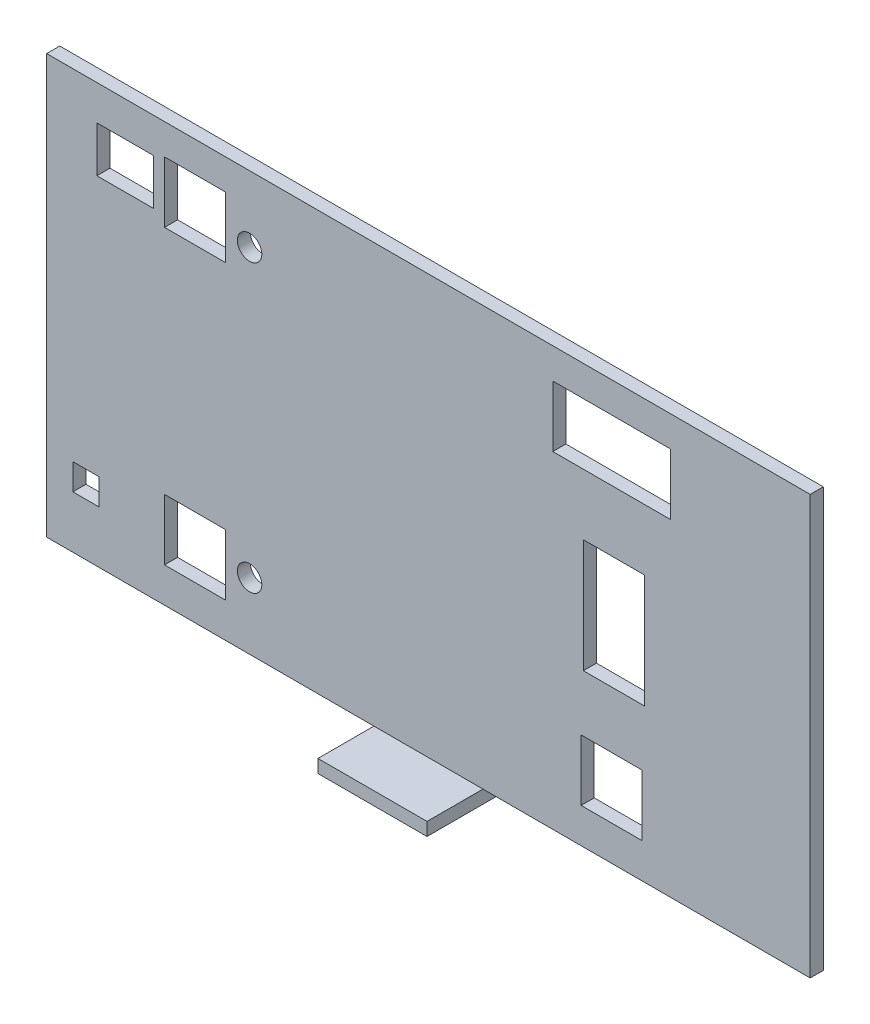
from build123d import *

# Parameters (mm, degrees)
SKETCH2_W           = 175
SKETCH2_H           = 96
BOSS_EXTRUDE1_DEPTH = 3
SKETCH3_W           = 12
SKETCH3_H           = 12
SKETCH3_W_2         = 13
SKETCH3_H_2         = 10.5
SKETCH3_W_3         = 27
SKETCH3_H_3         = 14
CUT_EXTRUDE1_DEPTH  = 10
SKETCH4_W           = 14
SKETCH4_H           = 26
CUT_EXTRUDE2_DEPTH  = 10
SKETCH5_W           = 12
SKETCH5_H           = 12
SKETCH5_W_2         = 6
SKETCH5_H_2         = 6
CUT_EXTRUDE3_DEPTH  = 10
SKETCH7_R           = 2.8
CUT_EXTRUDE4_DEPTH  = 10
SKETCH9_W           = 25
SKETCH9_H           = 15.829859375
BOSS_EXTRUDE2_DEPTH = 3
SKETCH10_W          = 27
SKETCH10_H          = 14
CUT_EXTRUDE5_DEPTH  = 10
SKETCH11_W          = 14
SKETCH11_H          = 14
CUT_EXTRUDE6_DEPTH  = 10
SKETCH12_W          = 14
SKETCH12_H          = 14
CUT_EXTRUDE7_DEPTH  = 10
SKETCH13_W          = 14
SKETCH13_H          = 14
CUT_EXTRUDE8_DEPTH  = 10


with BuildPart() as part:
    # Sketch2 → Boss-Extrude1 (new body)
    with BuildSketch(Plane.XY):
        Rectangle(SKETCH2_W, SKETCH2_H)
    extrude(amount=BOSS_EXTRUDE1_DEPTH)

    # Sketch3 → Cut-Extrude1 (cut)
    with BuildSketch(Plane(origin=(0, 0, 0), x_dir=(-1, 0, 0), z_dir=(0, 0, -1))):
        with Locations((53.5, 34)):
            Rectangle(SKETCH3_W, SKETCH3_H)
        with Locations((69.5, 34.75)):
            Rectangle(SKETCH3_W_2, SKETCH3_H_2)
        with Locations((-42, 34)):
            Rectangle(SKETCH3_W_3, SKETCH3_H_3)
        with Locations((-48.5, 34)):
            Rectangle(SKETCH3_W, SKETCH3_H, mode=Mode.SUBTRACT)
        with Locations((-35.5, 34)):
            Rectangle(SKETCH3_W, SKETCH3_H, mode=Mode.SUBTRACT)
    extrude(amount=-CUT_EXTRUDE1_DEPTH, mode=Mode.SUBTRACT)

    # Sketch4 → Cut-Extrude2 (cut)
    with BuildSketch(Plane(origin=(0, 0, 0), x_dir=(-1, 0, 0), z_dir=(0, 0, -1))):
        with Locations((-42.5, 0)):
            Rectangle(SKETCH4_W, SKETCH4_H)
    extrude(amount=-CUT_EXTRUDE2_DEPTH, mode=Mode.SUBTRACT)

    # Sketch5 → Cut-Extrude3 (cut)
    with BuildSketch(Plane(origin=(0, 0, 0), x_dir=(-1, 0, 0), z_dir=(0, 0, -1))):
        with Locations((-42, -33)):
            Rectangle(SKETCH5_W, SKETCH5_H)
        with Locations((53.5, -33)):
            Rectangle(SKETCH5_W, SKETCH5_H)
        with Locations((78.5, -33)):
            Rectangle(SKETCH5_W_2, SKETCH5_H_2)
    extrude(amount=-CUT_EXTRUDE3_DEPTH, mode=Mode.SUBTRACT)

    # Sketch7 → Cut-Extrude4 (cut)
    with BuildSketch(Plane(origin=(0, 0, 0), x_dir=(-1, 0, 0), z_dir=(0, 0, -1))):
        with Locations((41, 32.8)):
            Circle(SKETCH7_R)
        with Locations((41, -32.8)):
            Circle(SKETCH7_R)
    extrude(amount=-CUT_EXTRUDE4_DEPTH, mode=Mode.SUBTRACT)

    # Sketch9 → Boss-Extrude2 (add)
    with BuildSketch(Plane.XZ.offset(48)):
        with Locations((0, 7.914929688)):
            Rectangle(SKETCH9_W, SKETCH9_H)
    extrude(amount=BOSS_EXTRUDE2_DEPTH)

    # Sketch10 → Cut-Extrude5 (cut)
    with BuildSketch(Plane(origin=(0, 0, 0), x_dir=(-1, 0, 0), z_dir=(0, 0, -1))):
        with Locations((-42, 34)):
            Rectangle(SKETCH10_W, SKETCH10_H)
    extrude(amount=-CUT_EXTRUDE5_DEPTH, mode=Mode.SUBTRACT)

    # Sketch11 → Cut-Extrude6 (cut)
    with BuildSketch(Plane(origin=(0, 0, 0), x_dir=(-1, 0, 0), z_dir=(0, 0, -1))):
        with Locations((53.5, 34)):
            Rectangle(SKETCH11_W, SKETCH11_H)
    extrude(amount=-CUT_EXTRUDE6_DEPTH, mode=Mode.SUBTRACT)

    # Sketch12 → Cut-Extrude7 (cut)
    with BuildSketch(Plane(origin=(0, 0, 0), x_dir=(-1, 0, 0), z_dir=(0, 0, -1))):
        with Locations((53.5, -33)):
            Rectangle(SKETCH12_W, SKETCH12_H)
    extrude(amount=-CUT_EXTRUDE7_DEPTH, mode=Mode.SUBTRACT)

    # Sketch13 → Cut-Extrude8 (cut)
    with BuildSketch(Plane(origin=(0, 0, 0), x_dir=(-1, 0, 0), z_dir=(0, 0, -1))):
        with Locations((-42, -33)):
            Rectangle(SKETCH13_W, SKETCH13_H)
    extrude(amount=-CUT_EXTRUDE8_DEPTH, mode=Mode.SUBTRACT)


solid = part.part
